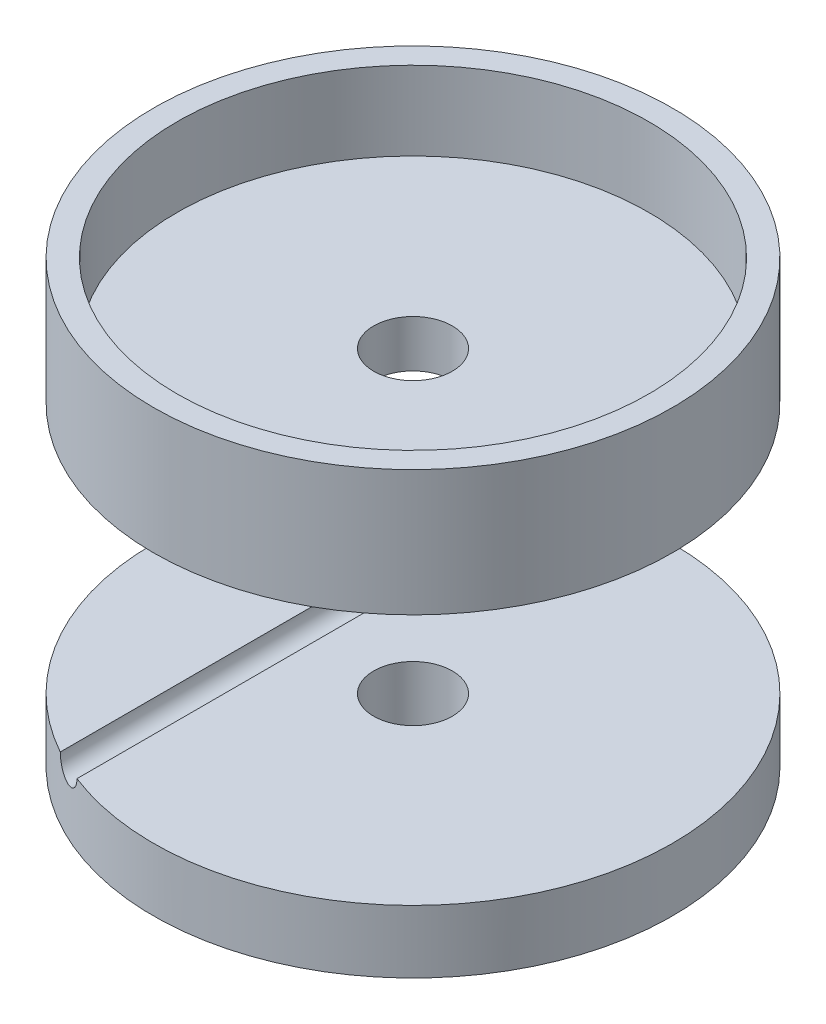
from build123d import *

# Parameters (mm, degrees)
SCHIZZO1_R                    = 15
SCHIZZO1_R_2                  = 2.5
ESTRUSIONE_ESTRUSIONE1_DEPTH  = 3
SCHIZZO1_5_R                  = 16.5
SCHIZZO1_5_R_2                = 15
ESTRUSIONE_ESTRUSIONE2_DEPTH  = 8
SCHIZZO4_R                    = 16.5
SCHIZZO4_R_2                  = 2.5
ESTRUSIONE_ESTRUSIONE3_DEPTH  = 4
TAGLIO_ESTRUSIONE1_DEPTH      = 31.732718721
TAGLIO_ESTRUSIONE1_DEPTH_BACK = 31.732718721
SCHIZZO5_R                    = 1


with BuildPart() as part:
    # Schizzo1 → Estrusione-Estrusione1 (new body)
    with BuildSketch(Plane(origin=(0, 0, 0), x_dir=(1, 0, 0), z_dir=(0, 1, 0))):
        Circle(SCHIZZO1_R)
        Circle(SCHIZZO1_R_2, mode=Mode.SUBTRACT)
    extrude(amount=ESTRUSIONE_ESTRUSIONE1_DEPTH)

    # Schizzo1_5 → Estrusione-Estrusione2 (add)
    with BuildSketch(Plane(origin=(0, 0, 0), x_dir=(1, 0, 0), z_dir=(0, 1, 0))):
        Circle(SCHIZZO1_5_R)
        Circle(SCHIZZO1_5_R_2, mode=Mode.SUBTRACT)
    extrude(amount=ESTRUSIONE_ESTRUSIONE2_DEPTH)


with BuildPart() as body_2:
    # Schizzo4 → Estrusione-Estrusione3 (new body)
    with BuildSketch(Plane(origin=(0, -20, 0), x_dir=(-1, 0, 0), z_dir=(0, -1, 0))):
        Circle(SCHIZZO4_R)
        Circle(SCHIZZO4_R_2, mode=Mode.SUBTRACT)
    extrude(amount=-ESTRUSIONE_ESTRUSIONE3_DEPTH)

    # Schizzo5 → Taglio-Estrusione1 (cut, two sides: drawn at the far end of the back side and taken through both)
    with BuildSketch(Plane.XY.offset(-TAGLIO_ESTRUSIONE1_DEPTH_BACK)):
        with Locations((-7, -16)):
            Circle(SCHIZZO5_R)
    extrude(amount=TAGLIO_ESTRUSIONE1_DEPTH + TAGLIO_ESTRUSIONE1_DEPTH_BACK, mode=Mode.SUBTRACT)


solid = Compound([part.part, body_2.part])
